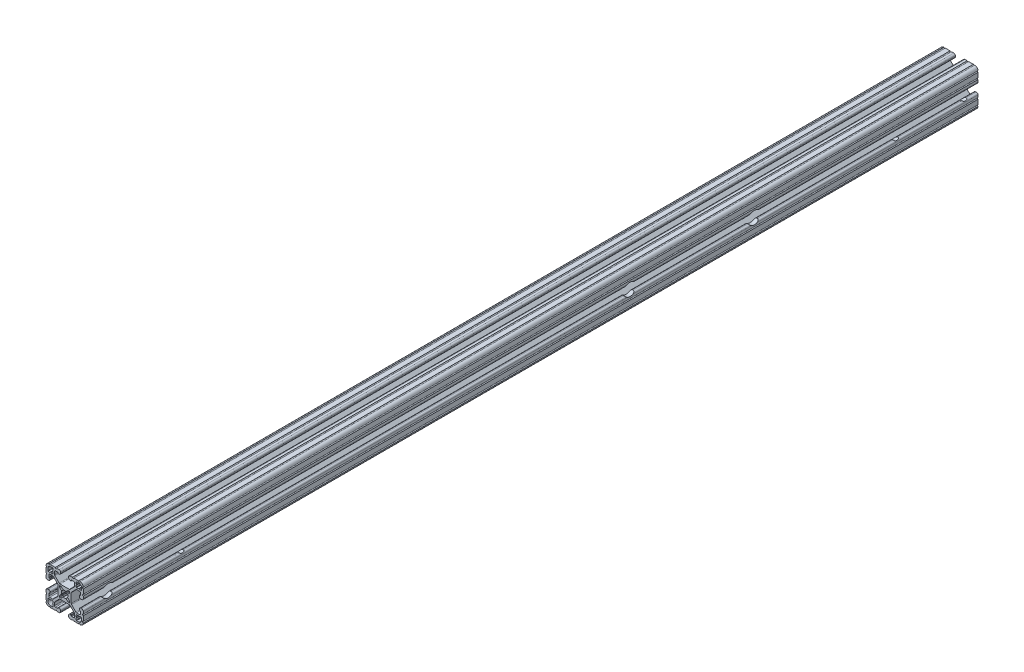
from build123d import *

# Parameters (mm, degrees)
BOSS_EXTRUDE1_DEPTH = 914.4
SKETCH3_R           = 4.7625
SKETCH3_R_2         = 6.35
CUT_EXTRUDE1_DEPTH  = 39.100000018


with BuildPart() as part:
    # Sketch1 → Boss-Extrude1 (new body)
    with BuildSketch(Plane(origin=(0, 0, -2322.576), x_dir=(-1, 0, 0), z_dir=(0, 0, -1))):
        with BuildLine():
            Line((19.05, -14.325600033), (19.05, -9.4996))
            ThreePointArc((19.05, -9.4996), (18.288, -8.7376), (19.05, -7.9756))
            Line((19.05, -7.9756), (19.05, -5.6388))
            ThreePointArc((19.05, -5.6388), (18.588751759, -4.525248241), (17.4752, -4.064))
            Line((17.4752, -4.064), (16.5608, -4.064))
            ThreePointArc((16.5608, -4.064), (15.447248241, -4.525248241), (14.986, -5.6388))
            Line((14.986, -5.6388), (14.986, -6.350014224))
            ThreePointArc((14.986, -6.350014224), (15.097592316, -6.619421908), (15.367, -6.731014224))
            Line((15.367, -6.731014224), (15.6972, -6.731014224))
            ThreePointArc((15.6972, -6.731014224), (15.966607684, -6.84260654), (16.0782, -7.112014224))
            Line((16.0782, -7.112014224), (16.0782, -9.398014224))
            ThreePointArc((16.0782, -9.398014224), (15.817817928, -10.026632152), (15.1892, -10.287014224))
            Line((15.1892, -10.287014224), (12.375630013, -10.287014224))
            ThreePointArc((12.375630013, -10.287014224), (11.889622054, -10.19034123), (11.477604401, -9.915039836))
            Line((11.477604401, -9.915039836), (7.115699788, -5.553135223))
            ThreePointArc((7.115699788, -5.553135223), (6.840398394, -5.14111757), (6.7437254, -4.655109611))
            Line((6.7437254, -4.655109611), (6.7437254, 4.655109611))
            ThreePointArc((6.7437254, 4.655109611), (6.840398394, 5.14111757), (7.115699788, 5.553135223))
            Line((7.115699788, 5.553135223), (11.477604401, 9.915039836))
            ThreePointArc((11.477604401, 9.915039836), (11.889622054, 10.19034123), (12.375630013, 10.287014224))
            Line((12.375630013, 10.287014224), (15.1892, 10.287014224))
            ThreePointArc((15.1892, 10.287014224), (15.817817928, 10.026632152), (16.0782, 9.398014224))
            Line((16.0782, 9.398014224), (16.0782, 7.112014224))
            ThreePointArc((16.0782, 7.112014224), (15.966607684, 6.84260654), (15.6972, 6.731014224))
            Line((15.6972, 6.731014224), (15.367, 6.731014224))
            ThreePointArc((15.367, 6.731014224), (15.097592316, 6.619421908), (14.986, 6.350014224))
            Line((14.986, 6.350014224), (14.986, 5.6388))
            ThreePointArc((14.986, 5.6388), (15.447248241, 4.525248241), (16.5608, 4.064))
            Line((16.5608, 4.064), (17.4752, 4.064))
            ThreePointArc((17.4752, 4.064), (18.588751759, 4.525248241), (19.05, 5.6388))
            Line((19.05, 5.6388), (19.05, 7.9756))
            ThreePointArc((19.05, 7.9756), (18.288, 8.7376), (19.05, 9.4996))
            Line((19.05, 9.4996), (19.05, 14.325599984))
            ThreePointArc((19.05, 14.325599984), (18.287999986, 15.087549208), (19.049898416, 15.849600009))
            ThreePointArc((19.049898416, 15.849600009), (18.120064036, 18.120064058), (15.849599977, 19.049898414))
            ThreePointArc((15.849599977, 19.049898414), (15.0875492, 18.288000035), (14.325600017, 19.050000016))
            Line((14.325600017, 19.050000016), (9.499600001, 19.050000016))
            ThreePointArc((9.499600001, 19.050000016), (8.737600001, 18.288000016), (7.975600001, 19.050000016))
            Line((7.975600001, 19.050000016), (5.638800016, 19.050000016))
            ThreePointArc((5.638800016, 19.050000016), (4.525248257, 18.588751775), (4.064000016, 17.475200016))
            Line((4.064000016, 17.475200016), (4.064000016, 16.5608))
            ThreePointArc((4.064000016, 16.5608), (4.525248257, 15.447248241), (5.638800016, 14.986))
            Line((5.638800016, 14.986), (6.350014224, 14.986))
            ThreePointArc((6.350014224, 14.986), (6.619421908, 15.097592316), (6.731014224, 15.367))
            Line((6.731014224, 15.367), (6.731014224, 15.6972))
            ThreePointArc((6.731014224, 15.6972), (6.84260654, 15.966607684), (7.112014224, 16.0782))
            Line((7.112014224, 16.0782), (9.398014224, 16.0782))
            ThreePointArc((9.398014224, 16.0782), (10.026632152, 15.817817928), (10.287014224, 15.1892))
            Line((10.287014224, 15.1892), (10.287014224, 12.375630013))
            ThreePointArc((10.287014224, 12.375630013), (10.19034123, 11.889622054), (9.915039836, 11.477604401))
            Line((9.915039836, 11.477604401), (5.553135223, 7.115699788))
            ThreePointArc((5.553135223, 7.115699788), (5.14111757, 6.840398394), (4.655109611, 6.7437254))
            Line((4.655109611, 6.7437254), (-4.655109611, 6.7437254))
            ThreePointArc((-4.655109611, 6.7437254), (-5.14111757, 6.840398394), (-5.553135223, 7.115699788))
            Line((-5.553135223, 7.115699788), (-9.915039836, 11.477604401))
            ThreePointArc((-9.915039836, 11.477604401), (-10.19034123, 11.889622054), (-10.287014224, 12.375630013))
            Line((-10.287014224, 12.375630013), (-10.287014224, 15.1892))
            ThreePointArc((-10.287014224, 15.1892), (-10.026632152, 15.817817928), (-9.398014224, 16.0782))
            Line((-9.398014224, 16.0782), (-7.112014224, 16.0782))
            ThreePointArc((-7.112014224, 16.0782), (-6.84260654, 15.966607684), (-6.731014224, 15.6972))
            Line((-6.731014224, 15.6972), (-6.731014224, 15.367))
            ThreePointArc((-6.731014224, 15.367), (-6.619421908, 15.097592316), (-6.350014224, 14.986))
            Line((-6.350014224, 14.986), (-5.638799984, 14.986))
            ThreePointArc((-5.638799984, 14.986), (-4.525248225, 15.447248241), (-4.063999984, 16.5608))
            Line((-4.063999984, 16.5608), (-4.063999984, 17.475200016))
            ThreePointArc((-4.063999984, 17.475200016), (-4.525248225, 18.588751775), (-5.638799984, 19.050000016))
            Line((-5.638799984, 19.050000016), (-7.975599999, 19.050000016))
            ThreePointArc((-7.975599999, 19.050000016), (-8.737599999, 18.288000016), (-9.499599999, 19.050000016))
            Line((-9.499599999, 19.050000016), (-14.325599999, 19.050000016))
            ThreePointArc((-14.325599999, 19.050000016), (-15.087549199, 18.288000018), (-15.849599993, 19.049898416))
            ThreePointArc((-15.849599993, 19.049898416), (-18.120064042, 18.120064036), (-19.049898398, 15.849599976))
            ThreePointArc((-19.049898398, 15.849599976), (-18.288000019, 15.087549199), (-19.05, 14.325600017))
            Line((-19.05, 14.325600017), (-19.05, 9.4996))
            ThreePointArc((-19.05, 9.4996), (-18.288, 8.7376), (-19.05, 7.9756))
            Line((-19.05, 7.9756), (-19.05, 5.6388))
            ThreePointArc((-19.05, 5.6388), (-18.588751759, 4.525248241), (-17.4752, 4.064))
            Line((-17.4752, 4.064), (-16.5608, 4.064))
            ThreePointArc((-16.5608, 4.064), (-15.447248241, 4.525248241), (-14.986, 5.6388))
            Line((-14.986, 5.6388), (-14.986, 6.350014224))
            ThreePointArc((-14.986, 6.350014224), (-15.097592316, 6.619421908), (-15.367, 6.731014224))
            Line((-15.367, 6.731014224), (-15.6972, 6.731014224))
            ThreePointArc((-15.6972, 6.731014224), (-15.966607684, 6.84260654), (-16.0782, 7.112014224))
            Line((-16.0782, 7.112014224), (-16.0782, 9.398014224))
            ThreePointArc((-16.0782, 9.398014224), (-15.817817928, 10.026632152), (-15.1892, 10.287014224))
            Line((-15.1892, 10.287014224), (-12.375630013, 10.287014224))
            ThreePointArc((-12.375630013, 10.287014224), (-11.889622054, 10.19034123), (-11.477604401, 9.915039836))
            Line((-11.477604401, 9.915039836), (-7.115699788, 5.553135223))
            ThreePointArc((-7.115699788, 5.553135223), (-6.840398394, 5.14111757), (-6.7437254, 4.655109611))
            Line((-6.7437254, 4.655109611), (-6.7437254, -4.655109611))
            ThreePointArc((-6.7437254, -4.655109611), (-6.840398394, -5.14111757), (-7.115699788, -5.553135223))
            Line((-7.115699788, -5.553135223), (-11.477604401, -9.915039836))
            ThreePointArc((-11.477604401, -9.915039836), (-11.889622054, -10.19034123), (-12.375630013, -10.287014224))
            Line((-12.375630013, -10.287014224), (-15.1892, -10.287014224))
            ThreePointArc((-15.1892, -10.287014224), (-15.817817928, -10.026632152), (-16.0782, -9.398014224))
            Line((-16.0782, -9.398014224), (-16.0782, -7.112014224))
            ThreePointArc((-16.0782, -7.112014224), (-15.966607684, -6.84260654), (-15.6972, -6.731014224))
            Line((-15.6972, -6.731014224), (-15.367, -6.731014224))
            ThreePointArc((-15.367, -6.731014224), (-15.097592316, -6.619421908), (-14.986, -6.350014224))
            Line((-14.986, -6.350014224), (-14.986, -5.6388))
            ThreePointArc((-14.986, -5.6388), (-15.447248241, -4.525248241), (-16.5608, -4.064))
            Line((-16.5608, -4.064), (-17.4752, -4.064))
            ThreePointArc((-17.4752, -4.064), (-18.588751759, -4.525248241), (-19.05, -5.6388))
            Line((-19.05, -5.6388), (-19.05, -7.9756))
            ThreePointArc((-19.05, -7.9756), (-18.288, -8.7376), (-19.05, -9.4996))
            Line((-19.05, -9.4996), (-19.05, -14.3256))
            ThreePointArc((-19.05, -14.3256), (-18.288000002, -15.0875492), (-19.0498984, -15.849599993))
            ThreePointArc((-19.0498984, -15.849599993), (-18.120064019, -18.120064043), (-15.84959996, -19.049898399))
            ThreePointArc((-15.84959996, -19.049898399), (-15.087549183, -18.288000019), (-14.325600001, -19.050000001))
            Line((-14.325600001, -19.050000001), (-9.499599984, -19.050000001))
            ThreePointArc((-9.499599984, -19.050000001), (-8.737599984, -18.288000001), (-7.975599984, -19.050000001))
            Line((-7.975599984, -19.050000001), (-5.638799984, -19.050000001))
            ThreePointArc((-5.638799984, -19.050000001), (-4.525248225, -18.58875176), (-4.063999984, -17.475200001))
            Line((-4.063999984, -17.475200001), (-4.063999984, -16.5608))
            ThreePointArc((-4.063999984, -16.5608), (-4.525248225, -15.447248241), (-5.638799984, -14.986))
            Line((-5.638799984, -14.986), (-6.350014224, -14.986))
            ThreePointArc((-6.350014224, -14.986), (-6.619421908, -15.097592316), (-6.731014224, -15.367))
            Line((-6.731014224, -15.367), (-6.731014224, -15.6972))
            ThreePointArc((-6.731014224, -15.6972), (-6.84260654, -15.966607684), (-7.112014224, -16.0782))
            Line((-7.112014224, -16.0782), (-9.398014224, -16.0782))
            ThreePointArc((-9.398014224, -16.0782), (-10.026632152, -15.817817928), (-10.287014224, -15.1892))
            Line((-10.287014224, -15.1892), (-10.287014224, -12.375630013))
            ThreePointArc((-10.287014224, -12.375630013), (-10.19034123, -11.889622054), (-9.915039836, -11.477604401))
            Line((-9.915039836, -11.477604401), (-5.553135223, -7.115699788))
            ThreePointArc((-5.553135223, -7.115699788), (-5.14111757, -6.840398394), (-4.655109611, -6.7437254))
            Line((-4.655109611, -6.7437254), (4.655109611, -6.7437254))
            ThreePointArc((4.655109611, -6.7437254), (5.14111757, -6.840398394), (5.553135223, -7.115699788))
            Line((5.553135223, -7.115699788), (9.915039836, -11.477604401))
            ThreePointArc((9.915039836, -11.477604401), (10.19034123, -11.889622054), (10.287014224, -12.375630013))
            Line((10.287014224, -12.375630013), (10.287014224, -15.1892))
            ThreePointArc((10.287014224, -15.1892), (10.026632152, -15.817817928), (9.398014224, -16.0782))
            Line((9.398014224, -16.0782), (7.112014224, -16.0782))
            ThreePointArc((7.112014224, -16.0782), (6.84260654, -15.966607684), (6.731014224, -15.6972))
            Line((6.731014224, -15.6972), (6.731014224, -15.367))
            ThreePointArc((6.731014224, -15.367), (6.619421908, -15.097592316), (6.350014224, -14.986))
            Line((6.350014224, -14.986), (5.638800016, -14.986))
            ThreePointArc((5.638800016, -14.986), (4.525248257, -15.447248241), (4.064000016, -16.5608))
            Line((4.064000016, -16.5608), (4.064000016, -17.475200001))
            ThreePointArc((4.064000016, -17.475200001), (4.525248257, -18.58875176), (5.638800016, -19.050000001))
            Line((5.638800016, -19.050000001), (7.975600016, -19.050000001))
            ThreePointArc((7.975600016, -19.050000001), (8.737600016, -18.288000001), (9.499600016, -19.050000001))
            Line((9.499600016, -19.050000001), (14.325600016, -19.050000001))
            ThreePointArc((14.325600016, -19.050000001), (15.087549216, -18.288000002), (15.849600009, -19.0498984))
            ThreePointArc((15.849600009, -19.0498984), (18.120064059, -18.12006402), (19.049898415, -15.849599961))
            ThreePointArc((19.049898415, -15.849599961), (18.288000034, -15.087549207), (19.05, -14.325600033))
        make_face()
        with BuildLine():
            Line((17.246614224, 14.452614224), (17.246614224, 12.242814224))
            ThreePointArc((17.246614224, 12.242814224), (17.135021908, 11.97340654), (16.865614224, 11.861814224))
            Line((16.865614224, 11.861814224), (15.092694224, 11.861814224))
            Line((15.092694224, 11.861814224), (14.554214224, 12.400294224))
            Line((14.554214224, 12.400294224), (14.015734224, 11.861814224))
            Line((14.015734224, 11.861814224), (12.242814224, 11.861814224))
            ThreePointArc((12.242814224, 11.861814224), (11.97340654, 11.97340654), (11.861814224, 12.242814224))
            Line((11.861814224, 12.242814224), (11.861814224, 14.015734224))
            Line((11.861814224, 14.015734224), (12.400294224, 14.554214224))
            Line((12.400294224, 14.554214224), (11.861814224, 15.092694224))
            Line((11.861814224, 15.092694224), (11.861814224, 16.865614224))
            ThreePointArc((11.861814224, 16.865614224), (11.97340654, 17.135021908), (12.242814224, 17.246614224))
            Line((12.242814224, 17.246614224), (14.452614224, 17.246614224))
            ThreePointArc((14.452614224, 17.246614224), (16.428270571, 16.428270571), (17.246614224, 14.452614224))
        make_face(mode=Mode.SUBTRACT)
        with BuildLine():
            Line((17.246614224, -12.242814224), (17.246614224, -14.452614224))
            ThreePointArc((17.246614224, -14.452614224), (16.428270571, -16.428270571), (14.452614224, -17.246614224))
            Line((14.452614224, -17.246614224), (12.242814224, -17.246614224))
            ThreePointArc((12.242814224, -17.246614224), (11.97340654, -17.135021908), (11.861814224, -16.865614224))
            Line((11.861814224, -16.865614224), (11.861814224, -15.092694224))
            Line((11.861814224, -15.092694224), (12.400294224, -14.554214224))
            Line((12.400294224, -14.554214224), (11.861814224, -14.015734224))
            Line((11.861814224, -14.015734224), (11.861814224, -12.242814224))
            ThreePointArc((11.861814224, -12.242814224), (11.97340654, -11.97340654), (12.242814224, -11.861814224))
            Line((12.242814224, -11.861814224), (14.015734224, -11.861814224))
            Line((14.015734224, -11.861814224), (14.554214224, -12.400294224))
            Line((14.554214224, -12.400294224), (15.092694224, -11.861814224))
            Line((15.092694224, -11.861814224), (16.865614224, -11.861814224))
            ThreePointArc((16.865614224, -11.861814224), (17.135021908, -11.97340654), (17.246614224, -12.242814224))
        make_face(mode=Mode.SUBTRACT)
        with BuildLine():
            Line((5.1689, -3.920689755), (5.1689, -4.9149))
            ThreePointArc((5.1689, -4.9149), (5.094505122, -5.094505122), (4.9149, -5.1689))
            Line((4.9149, -5.1689), (3.920689755, -5.1689))
            ThreePointArc((3.920689755, -5.1689), (3.580484184, -5.101228904), (3.292071827, -4.908517928))
            Line((3.292071827, -4.908517928), (1.582347442, -3.198793543))
            ThreePointArc((1.582347442, -3.198793543), (1.393016011, -3.095711236), (1.178048687, -3.111879183))
            ThreePointArc((1.178048687, -3.111879183), (0, -3.3274), (-1.178048687, -3.111879183))
            ThreePointArc((-1.178048687, -3.111879183), (-1.393016011, -3.095711236), (-1.582347442, -3.198793543))
            Line((-1.582347442, -3.198793543), (-3.292071827, -4.908517928))
            ThreePointArc((-3.292071827, -4.908517928), (-3.580484184, -5.101228904), (-3.920689755, -5.1689))
            Line((-3.920689755, -5.1689), (-4.9149, -5.1689))
            ThreePointArc((-4.9149, -5.1689), (-5.094505122, -5.094505122), (-5.1689, -4.9149))
            Line((-5.1689, -4.9149), (-5.1689, -3.920689755))
            ThreePointArc((-5.1689, -3.920689755), (-5.101228904, -3.580484184), (-4.908517928, -3.292071827))
            Line((-4.908517928, -3.292071827), (-3.198793543, -1.582347442))
            ThreePointArc((-3.198793543, -1.582347442), (-3.095711236, -1.393016011), (-3.111879183, -1.178048687))
            ThreePointArc((-3.111879183, -1.178048687), (-3.3274, 0), (-3.111879183, 1.178048687))
            ThreePointArc((-3.111879183, 1.178048687), (-3.095711236, 1.393016011), (-3.198793543, 1.582347442))
            Line((-3.198793543, 1.582347442), (-4.908517928, 3.292071827))
            ThreePointArc((-4.908517928, 3.292071827), (-5.101228904, 3.580484184), (-5.1689, 3.920689755))
            Line((-5.1689, 3.920689755), (-5.1689, 4.9149))
            ThreePointArc((-5.1689, 4.9149), (-5.094505122, 5.094505122), (-4.9149, 5.1689))
            Line((-4.9149, 5.1689), (-3.920689755, 5.1689))
            ThreePointArc((-3.920689755, 5.1689), (-3.580484184, 5.101228904), (-3.292071827, 4.908517928))
            Line((-3.292071827, 4.908517928), (-1.582347442, 3.198793543))
            ThreePointArc((-1.582347442, 3.198793543), (-1.393016011, 3.095711236), (-1.178048687, 3.111879183))
            ThreePointArc((-1.178048687, 3.111879183), (0, 3.3274), (1.178048687, 3.111879183))
            ThreePointArc((1.178048687, 3.111879183), (1.393016011, 3.095711236), (1.582347442, 3.198793543))
            Line((1.582347442, 3.198793543), (3.292071827, 4.908517928))
            ThreePointArc((3.292071827, 4.908517928), (3.580484184, 5.101228904), (3.920689755, 5.1689))
            Line((3.920689755, 5.1689), (4.9149, 5.1689))
            ThreePointArc((4.9149, 5.1689), (5.094505122, 5.094505122), (5.1689, 4.9149))
            Line((5.1689, 4.9149), (5.1689, 3.920689755))
            ThreePointArc((5.1689, 3.920689755), (5.101228904, 3.580484184), (4.908517928, 3.292071827))
            Line((4.908517928, 3.292071827), (3.198793543, 1.582347442))
            ThreePointArc((3.198793543, 1.582347442), (3.095711236, 1.393016011), (3.111879183, 1.178048687))
            ThreePointArc((3.111879183, 1.178048687), (3.3274, 0), (3.111879183, -1.178048687))
            ThreePointArc((3.111879183, -1.178048687), (3.095711236, -1.393016011), (3.198793543, -1.582347442))
            Line((3.198793543, -1.582347442), (4.908517928, -3.292071827))
            ThreePointArc((4.908517928, -3.292071827), (5.101228904, -3.580484184), (5.1689, -3.920689755))
        make_face(mode=Mode.SUBTRACT)
        with BuildLine():
            Line((-11.861814224, -12.242814224), (-11.861814224, -14.015734224))
            Line((-11.861814224, -14.015734224), (-12.400294224, -14.554214224))
            Line((-12.400294224, -14.554214224), (-11.861814224, -15.092694224))
            Line((-11.861814224, -15.092694224), (-11.861814224, -16.865614224))
            ThreePointArc((-11.861814224, -16.865614224), (-11.97340654, -17.135021908), (-12.242814224, -17.246614224))
            Line((-12.242814224, -17.246614224), (-14.452614224, -17.246614224))
            ThreePointArc((-14.452614224, -17.246614224), (-16.428270571, -16.428270571), (-17.246614224, -14.452614224))
            Line((-17.246614224, -14.452614224), (-17.246614224, -12.242814224))
            ThreePointArc((-17.246614224, -12.242814224), (-17.135021908, -11.97340654), (-16.865614224, -11.861814224))
            Line((-16.865614224, -11.861814224), (-15.092694224, -11.861814224))
            Line((-15.092694224, -11.861814224), (-14.554214224, -12.400294224))
            Line((-14.554214224, -12.400294224), (-14.015734224, -11.861814224))
            Line((-14.015734224, -11.861814224), (-12.242814224, -11.861814224))
            ThreePointArc((-12.242814224, -11.861814224), (-11.97340654, -11.97340654), (-11.861814224, -12.242814224))
        make_face(mode=Mode.SUBTRACT)
        with BuildLine():
            Line((-11.861814224, 16.865614224), (-11.861814224, 15.092694224))
            Line((-11.861814224, 15.092694224), (-12.400294224, 14.554214224))
            Line((-12.400294224, 14.554214224), (-11.861814224, 14.015734224))
            Line((-11.861814224, 14.015734224), (-11.861814224, 12.242814224))
            ThreePointArc((-11.861814224, 12.242814224), (-11.97340654, 11.97340654), (-12.242814224, 11.861814224))
            Line((-12.242814224, 11.861814224), (-14.015734224, 11.861814224))
            Line((-14.015734224, 11.861814224), (-14.554214224, 12.400294224))
            Line((-14.554214224, 12.400294224), (-15.092694224, 11.861814224))
            Line((-15.092694224, 11.861814224), (-16.865614224, 11.861814224))
            ThreePointArc((-16.865614224, 11.861814224), (-17.135021908, 11.97340654), (-17.246614224, 12.242814224))
            Line((-17.246614224, 12.242814224), (-17.246614224, 14.452614224))
            ThreePointArc((-17.246614224, 14.452614224), (-16.428270571, 16.428270571), (-14.452614224, 17.246614224))
            Line((-14.452614224, 17.246614224), (-12.242814224, 17.246614224))
            ThreePointArc((-12.242814224, 17.246614224), (-11.97340654, 17.135021908), (-11.861814224, 16.865614224))
        make_face(mode=Mode.SUBTRACT)
    extrude(amount=-BOSS_EXTRUDE1_DEPTH)

    # Sketch3 → Cut-Extrude1 (cut, through all)
    with BuildSketch(Plane(origin=(19.05, 0, 0), x_dir=(0, 0, -1), z_dir=(1, 0, 0))):
        with Locations((2309.876, 0)):
            Circle(SKETCH3_R)
        with Locations((2240.026, 0)):
            Circle(SKETCH3_R)
        with Locations((2093.976, 0)):
            Circle(SKETCH3_R_2)
        with Locations((1966.976, 0)):
            Circle(SKETCH3_R_2)
        with Locations((1433.576, 0)):
            Circle(SKETCH3_R_2)
        with Locations((1509.776, 0)):
            Circle(SKETCH3_R)
    extrude(amount=-CUT_EXTRUDE1_DEPTH, mode=Mode.SUBTRACT)


solid = part.part
